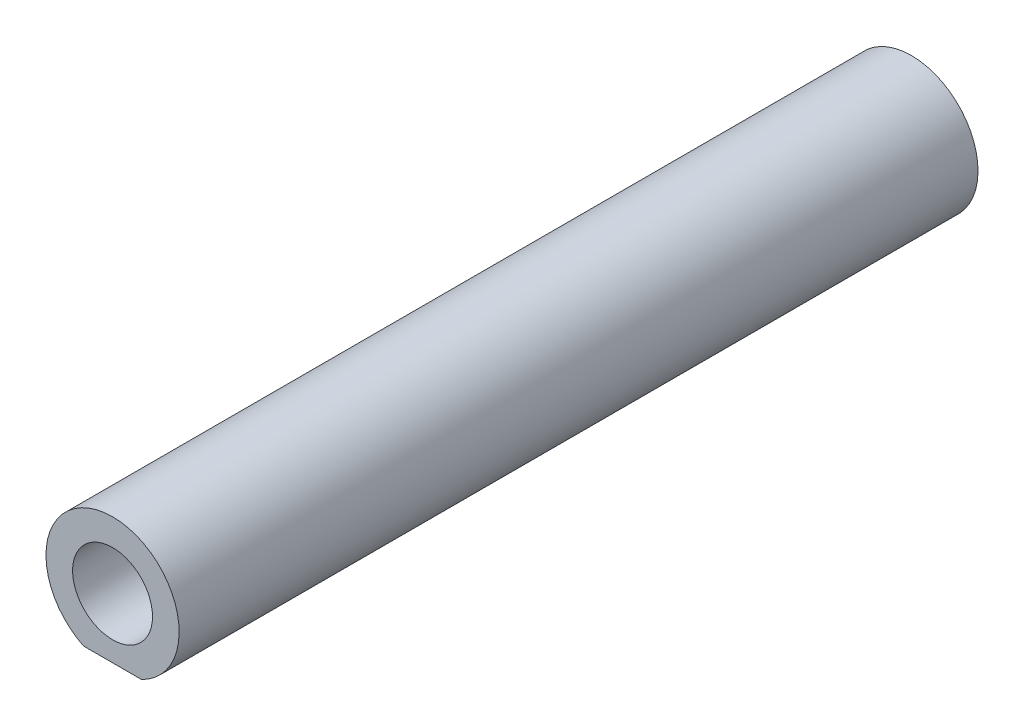
from build123d import *

# Parameters (mm, degrees)
SKETCH1_R           = 5
SKETCH1_R_2         = 3
BOSS_EXTRUDE1_DEPTH = 30
CUT_EXTRUDE2_DEPTH  = 10


with BuildPart() as part:
    # Sketch1 → Boss-Extrude1 (new body, symmetric)
    with BuildSketch(Plane.XY):
        Circle(SKETCH1_R)
        Circle(SKETCH1_R_2, mode=Mode.SUBTRACT)
    extrude(amount=BOSS_EXTRUDE1_DEPTH, both=True)

    # Sketch4 → Cut-Extrude2 (cut)
    with BuildSketch(Plane.XY.offset(30)):
        with BuildLine():
            Line((2.179449472, -4.5), (-2.179449472, -4.5))
            ThreePointArc((-2.179449472, -4.5), (0, -5), (2.179449472, -4.5))
        make_face()
    cut_extrude2 = extrude(amount=-CUT_EXTRUDE2_DEPTH, mode=Mode.SUBTRACT)

    # Mirror3: Cut-Extrude2 across plane
    add(cut_extrude2.mirror(Plane.XY), mode=Mode.SUBTRACT)


solid = part.part
